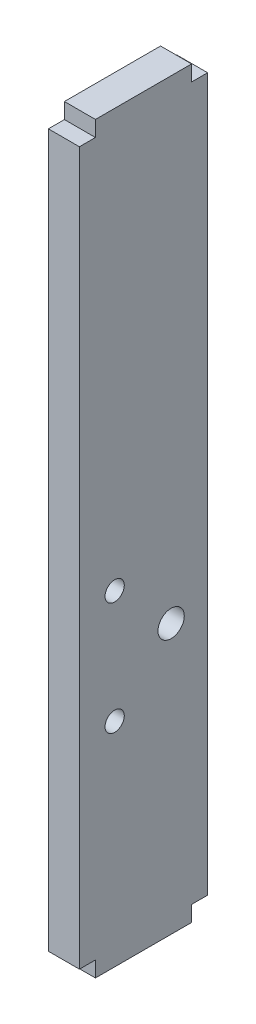
from build123d import *

# Parameters (mm, degrees)
CROQUIS1_R              = 2.05
CROQUIS1_R_2            = 1.5
SALIENTE_EXTRUIR1_DEPTH = 4.84


with BuildPart() as part:
    # Croquis1 → Saliente-Extruir1 (new body)
    with BuildSketch(Plane(origin=(0, 0, 0), x_dir=(0, 0, -1), z_dir=(1, 0, 0))):
        Polygon((-10, 0), (-10, 71.56), (-7.5, 71.56), (-7.5, 74), (7.5, 74), (7.5, 71.56), (10, 71.56), (10, -39.56), (7.5, -39.56), (7.5, -42), (-7.5, -42), (-7.5, -39.56), (-10, -39.56), align=None)
        with Locations((4.31, 0)):
            Circle(CROQUIS1_R, mode=Mode.SUBTRACT)
        with Locations((-4.5, 8.81)):
            Circle(CROQUIS1_R_2, mode=Mode.SUBTRACT)
        with Locations((-4.5, -8.81)):
            Circle(CROQUIS1_R_2, mode=Mode.SUBTRACT)
    extrude(amount=SALIENTE_EXTRUIR1_DEPTH)


solid = part.part
